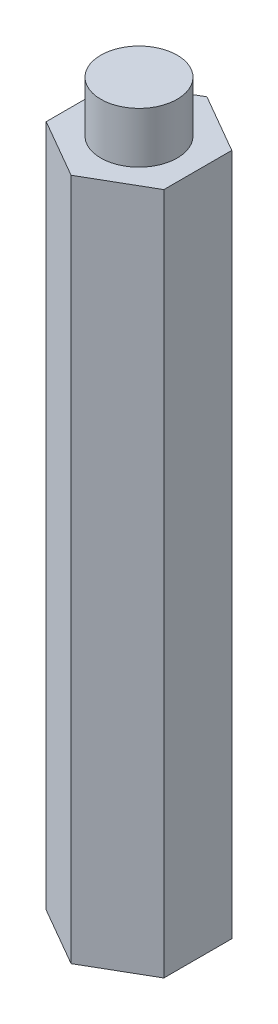
from build123d import *

# Parameters (mm, degrees)
BOSS_EXTRUDE1_DEPTH      = 40.21
SKETCH2_R                = 2.25
BOSS_EXTRUDE2_DEPTH      = 3
BOSS_EXTRUDE2_DEPTH_BACK = 30


with BuildPart() as part:
    # Sketch1 → Boss-Extrude1 (new body)
    with BuildSketch(Plane(origin=(0, 0, 0), x_dir=(1, 0, 0), z_dir=(0, 1, 0))):
        Polygon((0, -4), (3.464101615, -2), (3.464101615, 2), (0, 4), (-3.464101615, 2), (-3.464101615, -2), align=None)
    extrude(amount=BOSS_EXTRUDE1_DEPTH)

    # Sketch2 → Boss-Extrude2 (add, two sides)
    with BuildSketch(Plane(origin=(0, 40.21, 0), x_dir=(1, 0, 0), z_dir=(0, 1, 0))) as boss_extrude2_sk:
        Circle(SKETCH2_R)
    extrude(amount=BOSS_EXTRUDE2_DEPTH)
    extrude(boss_extrude2_sk.sketch, amount=-BOSS_EXTRUDE2_DEPTH_BACK)


solid = part.part
